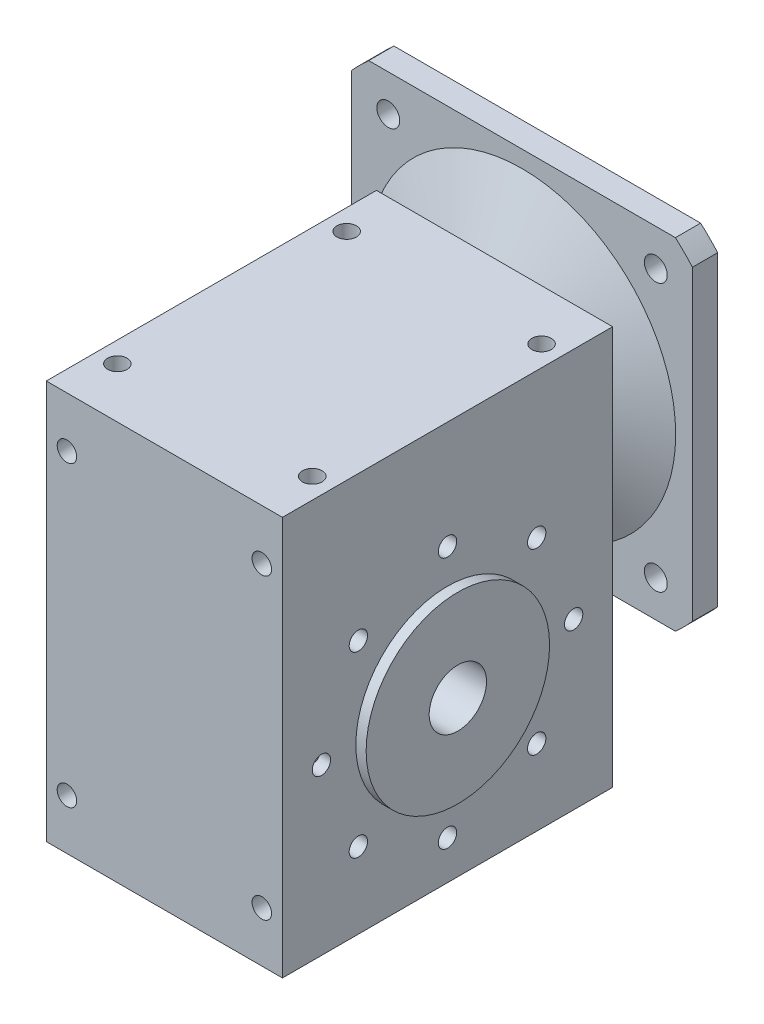
from build123d import *

# Parameters (mm, degrees)
SKETCH_1_W            = 103
SKETCH_1_H            = 144
EXTRUDE_1_DEPTH       = 174
SKETCH_3_R            = 12.5
CUT_EXTRUDE_1_DEPTH   = 104
SKETCH_4_R            = 4
CUT_EXTRUDE_2_DEPTH   = 104
SKETCH_5_R            = 4.25
CUT_EXTRUDE_3_DEPTH   = 175
SKETCH_7_W            = 70
SKETCH_7_H            = 140
CUT_EXTRUDE_4_DEPTH   = 169
SKETCH_8_R            = 40
SKETCH_8_R_2          = 12.5
EXTRUDE_2_DEPTH       = 56
SKETCH_9_R            = 4.25
CUT_EXTRUDE_5_DEPTH   = 144
SKETCH_10_R           = 5
CUT_EXTRUDE_6_DEPTH   = 17
SKETCH_11_OUTSIDE_W   = 272.176
SKETCH_11_OUTSIDE_H   = 307.176
SKETCH_11_OUTSIDE_W_2 = 148.672618896
SKETCH_11_OUTSIDE_H_2 = 148.672618896
CUT_EXTRUDE_7_DEPTH   = 17


with BuildPart() as part:
    # Эскиз1 → Бобышка-Вытянуть1 (new body)
    with BuildSketch(Plane(origin=(0, 0, 0), x_dir=(1, 0, 0), z_dir=(0, 1, 0))):
        Rectangle(SKETCH_1_W, SKETCH_1_H)
    extrude(amount=EXTRUDE_1_DEPTH)

    # Эскиз3 → Вырез-Вытянуть1 (cut, through all)
    with BuildSketch(Plane(origin=(51.5, 0, 0), x_dir=(0, 0, -1), z_dir=(1, 0, 0))):
        with Locations((0, 72)):
            Circle(SKETCH_3_R)
    extrude(amount=-CUT_EXTRUDE_1_DEPTH, mode=Mode.SUBTRACT)

    # Эскиз4 → Вырез-Вытянуть2 (cut, through all)
    with BuildSketch(Plane(origin=(51.5, 0, 0), x_dir=(0, 0, -1), z_dir=(1, 0, 0))):
        with Locations((0, 127)):
            Circle(SKETCH_4_R)
        with Locations((38.890872965, 110.890872965)):
            Circle(SKETCH_4_R)
        with Locations((55, 72)):
            Circle(SKETCH_4_R)
        with Locations((38.890872965, 33.109127035)):
            Circle(SKETCH_4_R)
        with Locations((0, 17)):
            Circle(SKETCH_4_R)
        with Locations((-38.890872965, 33.109127035)):
            Circle(SKETCH_4_R)
        with Locations((-55, 72)):
            Circle(SKETCH_4_R)
        with Locations((-38.890872965, 110.890872965)):
            Circle(SKETCH_4_R)
    extrude(amount=-CUT_EXTRUDE_2_DEPTH, mode=Mode.SUBTRACT)

    # Эскиз5 → Вырез-Вытянуть3 (cut, through all)
    with BuildSketch(Plane(origin=(0, 174, 0), x_dir=(1, 0, 0), z_dir=(0, 1, 0))):
        with Locations((-42.5, 50)):
            Circle(SKETCH_5_R)
        with Locations((42.5, 50)):
            Circle(SKETCH_5_R)
        with Locations((42.5, -50)):
            Circle(SKETCH_5_R)
        with Locations((-42.5, -50)):
            Circle(SKETCH_5_R)
    extrude(amount=-CUT_EXTRUDE_3_DEPTH, mode=Mode.SUBTRACT)

    # Эскиз6 → Повернуть1 (revolve)
    with BuildSketch(Plane(origin=(0, 0, 0), x_dir=(0, 0, -1), z_dir=(1, 0, 0))):
        Polygon((89, 146), (72, 146), (72, 174), (84, 202), (84, 235), (95, 235), (95, 200), (89, 200), (79, 176.666666667), (79, 152.5), (89, 152.5), align=None)
    revolve(axis=Axis((0, 135, 119.057986515), (0, 0, -1)))

    # Эскиз7 → Вырез-Вытянуть4 (cut)
    with BuildSketch(Plane.XZ):
        Rectangle(SKETCH_7_W, SKETCH_7_H)
    extrude(amount=-CUT_EXTRUDE_4_DEPTH, mode=Mode.SUBTRACT)

    # Эскиз8 → Бобышка-Вытянуть2 (add, symmetric)
    with BuildSketch(Plane(origin=(0, 0, 0), x_dir=(0, 0, -1), z_dir=(1, 0, 0))):
        with Locations((0, 72)):
            Circle(SKETCH_8_R)
        with Locations((0, 72)):
            Circle(SKETCH_8_R_2, mode=Mode.SUBTRACT)
    extrude(amount=EXTRUDE_2_DEPTH, both=True)

    # Эскиз9 → Вырез-Вытянуть5 (cut)
    with BuildSketch(Plane.XY.offset(72)):
        with Locations((-42.5, 152)):
            Circle(SKETCH_9_R)
        with Locations((42.5, 152)):
            Circle(SKETCH_9_R)
        with Locations((42.5, 22)):
            Circle(SKETCH_9_R)
        with Locations((-42.5, 22)):
            Circle(SKETCH_9_R)
    extrude(amount=-CUT_EXTRUDE_5_DEPTH, mode=Mode.SUBTRACT)

    # Эскиз10 → Вырез-Вытянуть6 (cut)
    with BuildSketch(Plane(origin=(0, 0, -95), x_dir=(-1, 0, 0), z_dir=(0, 0, -1))):
        with Locations((-58.336309448, 193.336309448)):
            Circle(SKETCH_10_R)
        with Locations((58.336309448, 193.336309448)):
            Circle(SKETCH_10_R)
        with Locations((58.336309448, 76.663690552)):
            Circle(SKETCH_10_R)
        with Locations((-58.336309448, 76.663690552)):
            Circle(SKETCH_10_R)
    extrude(amount=-CUT_EXTRUDE_6_DEPTH, mode=Mode.SUBTRACT)

    # Эскиз11 outside → Вырез-Вытянуть7 (cut)
    with BuildSketch(Plane(origin=(0, 0, -95), x_dir=(-1, 0, 0), z_dir=(0, 0, -1))):
        with Locations((0, 117.5)):
            Rectangle(SKETCH_11_OUTSIDE_W, SKETCH_11_OUTSIDE_H)
        with Locations((0, 135)):
            Rectangle(SKETCH_11_OUTSIDE_W_2, SKETCH_11_OUTSIDE_H_2, mode=Mode.SUBTRACT)
    extrude(amount=-CUT_EXTRUDE_7_DEPTH, mode=Mode.SUBTRACT)


solid = part.part
